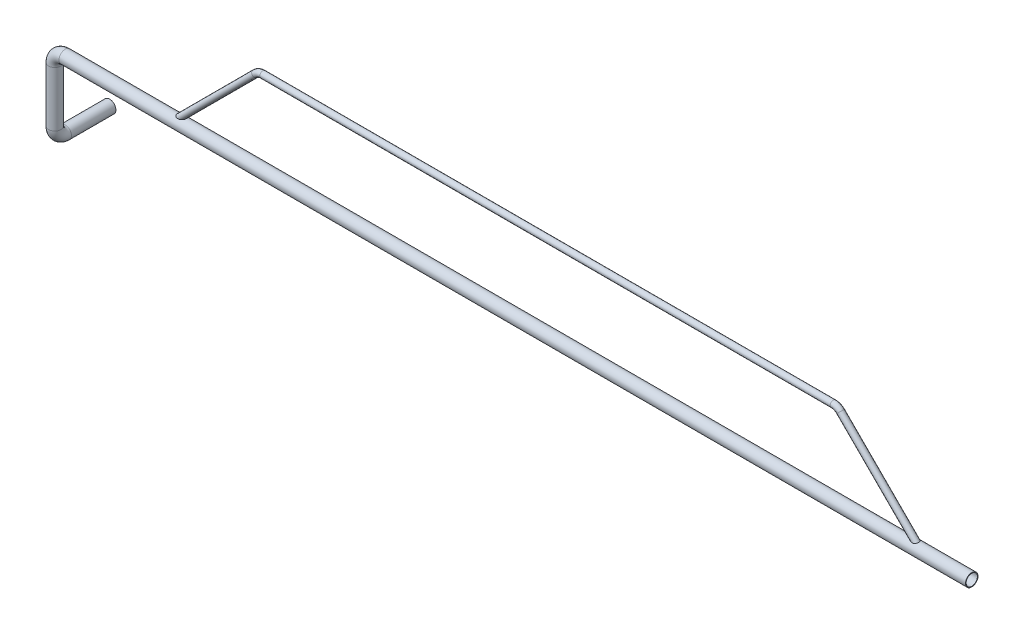
from build123d import *

# Parameters (mm, degrees)
SWEEP_THIN1_PROFILE_R   = 30
SWEEP_THIN1_PROFILE_R_2 = 27
SWEEP_THIN2_PROFILE_R   = 15
SWEEP_THIN2_PROFILE_R_2 = 12


with BuildPart() as part:
    # Sweep-Thin1: sweep along a curve in space
    with BuildLine() as sweep_thin1_path:
        Line((-24893.006183482, -8356.204513264, 39090.249256715), (-29246.554683292, -8356.204513264, 39090.249256715))
        ThreePointArc((-29296.554683292, -8406.204513264, 39090.249256715), (-29281.910022351, -8370.849174205, 39090.249256715), (-29246.554683292, -8356.204513264, 39090.249256715))
        Line((-29296.554683292, -8406.204513264, 39090.249256715), (-29296.554683292, -8670.518633414, 39090.249256715))
        ThreePointArc((-29296.554683292, -8720.518633414, 39040.249256715), (-29296.554683292, -8705.873972473, 39075.604595774), (-29296.554683292, -8670.518633414, 39090.249256715))
        Line((-29296.554683292, -8720.518633414, 39040.249256715), (-29296.554683292, -8720.518633414, 38826.890196057))
    # Sweep-Thin1 profile (on start of the path) → Sweep-Thin1 (sweep)
    with BuildSketch(Plane(origin=(-24893.006183482, -8356.204513264, 39090.249256715), x_dir=(0, 0, -1), z_dir=(-1, 0, 0))):
        Circle(SWEEP_THIN1_PROFILE_R)
        Circle(SWEEP_THIN1_PROFILE_R_2, mode=Mode.SUBTRACT)
    sweep(path=sweep_thin1_path.line)


with BuildPart() as body_2:
    # Sweep-Thin2: sweep along a curve in space
    with BuildLine() as sweep_thin2_path:
        Line((-25137.374453509, -8356.204513264, 39090.249256715), (-25522.729792568, -7970.849174205, 39090.249256715))
        ThreePointArc((-25558.085131628, -7956.204513264, 39090.249256715), (-25538.950960009, -7960.010536639, 39090.249256715), (-25522.729792568, -7970.849174205, 39090.249256715))
        Line((-25558.085131628, -7956.204513264, 39090.249256715), (-28297.486918384, -7956.204513264, 39090.249256715))
        ThreePointArc((-28297.486918384, -7956.204513264, 39090.249256715), (-28316.621090003, -7960.010536639, 39090.249256715), (-28332.842257444, -7970.849174205, 39090.249256715))
        Line((-28332.842257444, -7970.849174205, 39090.249256715), (-28718.197596503, -8356.204513264, 39090.249256715))
    # Sweep-Thin2 profile (on start of the path) → Sweep-Thin2 (sweep)
    with BuildSketch(Plane(origin=(-25137.374453509, -8356.204513264, 39090.249256715), x_dir=(0.7071067811865501, 0.707106781186545, 0), z_dir=(-0.707106781186545, 0.7071067811865501, 0))):
        Circle(SWEEP_THIN2_PROFILE_R)
        Circle(SWEEP_THIN2_PROFILE_R_2, mode=Mode.SUBTRACT)
    sweep(path=sweep_thin2_path.line)


solid = Compound([part.part, body_2.part])
